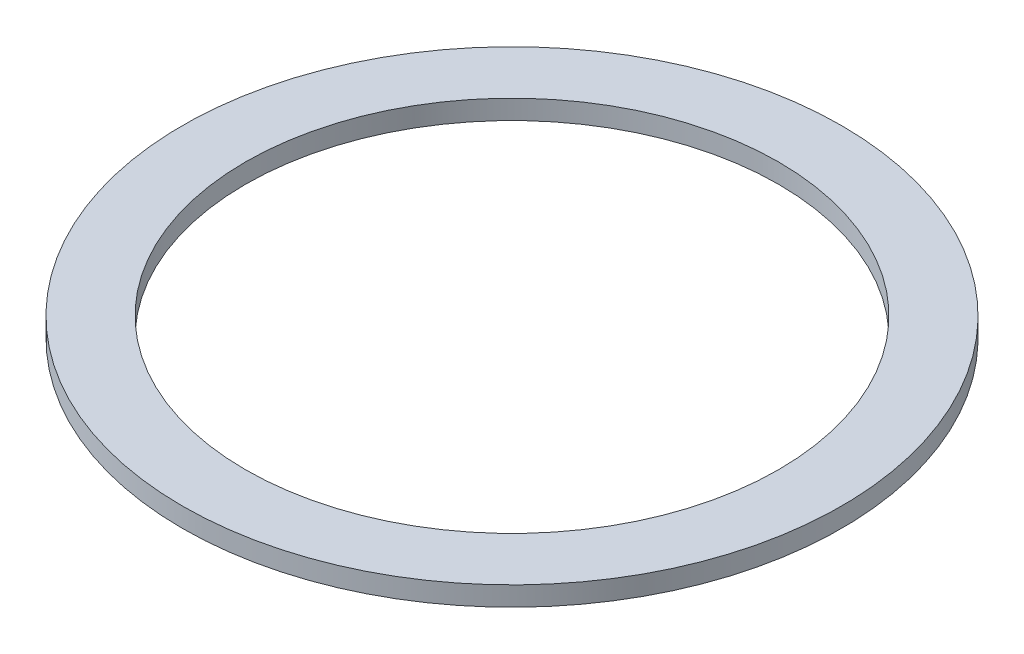
from build123d import *

# Parameters (mm, degrees)
SKETCH3_R                = 34
SKETCH3_R_2              = 27.5
BOSS_EXTRUDE1_DEPTH      = 1
BOSS_EXTRUDE1_DEPTH_BACK = 1


with BuildPart() as part:
    # Sketch3 → Boss-Extrude1 (new body, two sides)
    with BuildSketch(Plane(origin=(0, 0, 0), x_dir=(1, 0, 0), z_dir=(0, 1, 0))) as boss_extrude1_sk:
        Circle(SKETCH3_R)
        Circle(SKETCH3_R_2, mode=Mode.SUBTRACT)
    extrude(amount=BOSS_EXTRUDE1_DEPTH)
    extrude(boss_extrude1_sk.sketch, amount=-BOSS_EXTRUDE1_DEPTH_BACK)


solid = part.part
